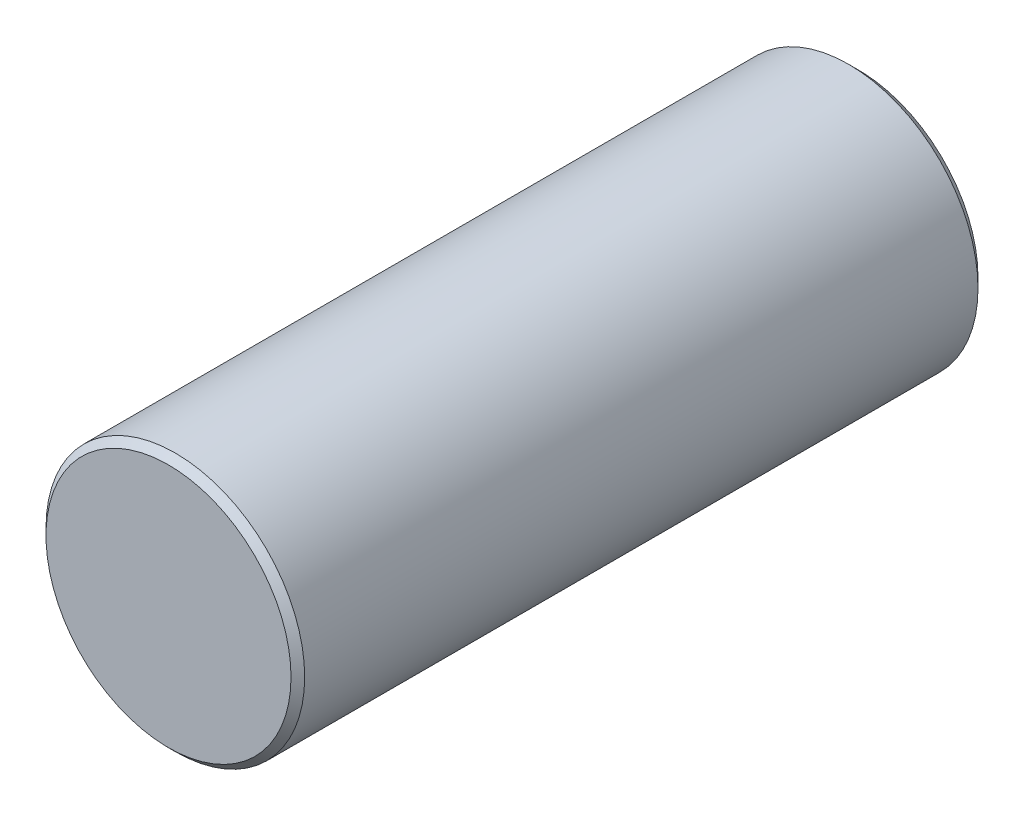
from build123d import *


with BuildPart() as part:
    # Sketch1 → Revolve1 (revolve)
    with BuildSketch(Plane(origin=(0, 0, 0), x_dir=(0, 0, -1), z_dir=(1, 0, 0))):
        Polygon((-12.7, 0), (-12.7, 4.511052829), (-12.448552829, 4.7625), (12.3444, 4.7625), (12.7, 4.4069), (12.7, 0), align=None)
    revolve(axis=Axis((0, 0, -12.7), (0, 0, 1)))


solid = part.part
